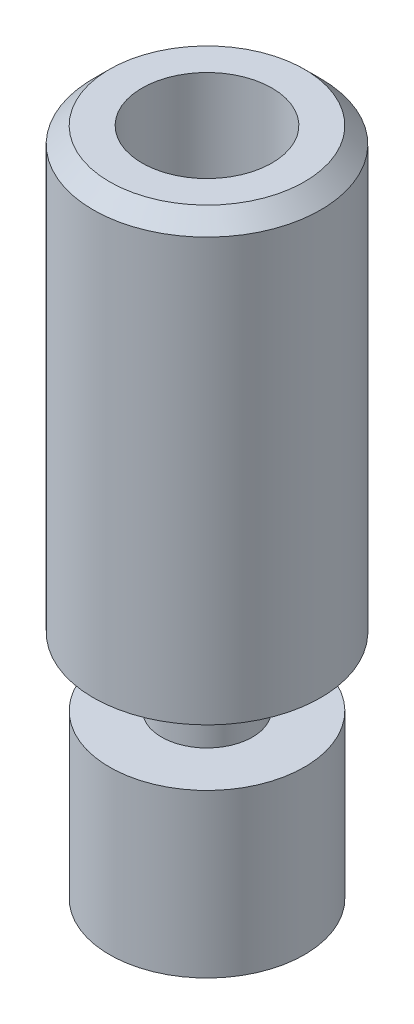
from build123d import *

# Parameters (mm, degrees)
CHAMFER1_SIZE = 0.5


with BuildPart() as part:
    # Sketch1 → Revolve1 (revolve)
    with BuildSketch(Plane.XY):
        Polygon((1, -10.3), (3, -10.3), (3, -5.3), (1.4, -5.3), (1.4, -3.2), (3.5, -3.2), (3.5, 10.3), (2, 10.3), (2, 6.3), (1, 5.722649731), align=None)
    revolve(axis=Axis((0, -10.3, 0), (0, 1, 0)))

    # Chamfer1
    chamfer1_edges = [part.edges().sort_by_distance(p)[0] for p in [
        (-3.5, 10.3, 0),
    ]]
    chamfer(chamfer1_edges, length=CHAMFER1_SIZE)


solid = part.part
